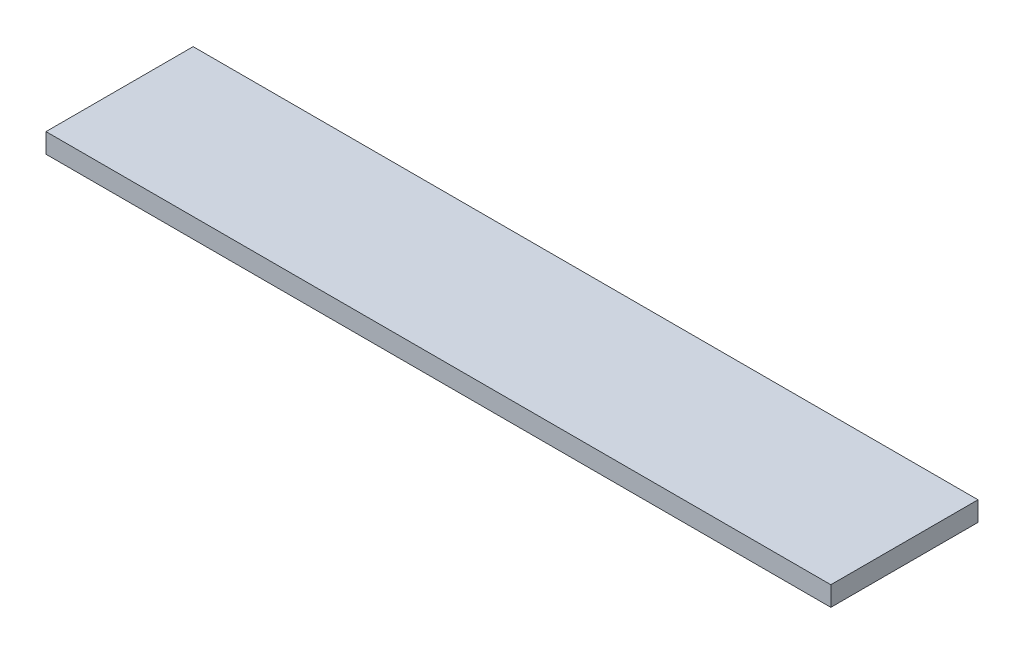
from build123d import *

# Parameters (mm, degrees)
SKETCH_1_W      = 800
SKETCH_1_H      = 150
EXTRUDE_1_DEPTH = 20


with BuildPart() as part:
    # Эскиз1 → Бобышка-Вытянуть1 (new body)
    with BuildSketch(Plane(origin=(0, 0, 0), x_dir=(1, 0, 0), z_dir=(0, 1, 0))):
        Rectangle(SKETCH_1_W, SKETCH_1_H)
    extrude(amount=EXTRUDE_1_DEPTH)


solid = part.part
